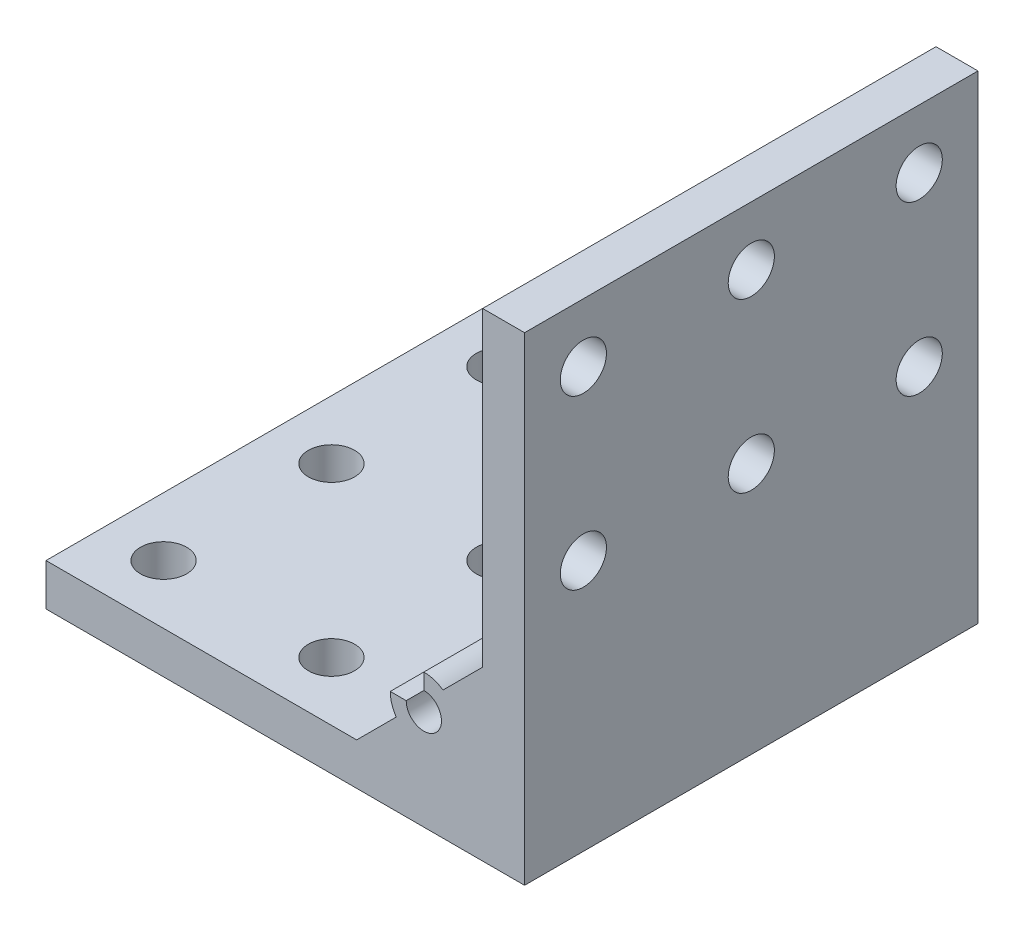
from build123d import *

# Parameters (mm, degrees)
BOSS_EXTRUDE1_DEPTH      = 27
BOSS_EXTRUDE1_DEPTH_BACK = 27
CUT_EXTRUDE1_REACH       = 79.479
SKETCH2_R                = 2.75
CUT_EXTRUDE2_REACH       = 79.479
SKETCH3_R                = 2.75


with BuildPart() as part:
    # Sketch1 → Boss-Extrude1 (new, two sides: drawn at the far end of the back side and taken through both)
    with BuildSketch(Plane.XY.offset(-BOSS_EXTRUDE1_DEPTH_BACK)):
        with BuildLine():
            Line((-8, -7), (-3.283882181, -2.283882181))
            ThreePointArc((-3.283882181, -2.283882181), (-3.816774078, -1.196760476), (-4, 0))
            Line((-4, 0), (-2.1, 0))
            ThreePointArc((-2.1, 0), (1.48492424, -1.48492424), (0, 2.1))
            Line((0, 2.1), (0, 4))
            ThreePointArc((0, 4), (1.196760476, 3.816774078), (2.283882181, 3.283882181))
            Line((2.283882181, 3.283882181), (7, 8))
            Line((7, 8), (7, 45))
            Line((7, 45), (12, 45))
            Line((12, 45), (12, -12))
            Line((12, -12), (-45, -12))
            Line((-45, -12), (-45, -7))
            Line((-45, -7), (-8, -7))
        make_face()
    extrude(amount=BOSS_EXTRUDE1_DEPTH + BOSS_EXTRUDE1_DEPTH_BACK)

    # Sketch2 → Cut-Extrude1 (cut, up to next)
    with BuildSketch(Plane(origin=(12, 0, 0), x_dir=(0, 0, -1), z_dir=(1, 0, 0)), mode=Mode.PRIVATE) as cut_extrude1_sk1:
        with Locations((-20, 38)):
            Circle(SKETCH2_R)
    cut_extrude1_tool1 = extrude(cut_extrude1_sk1.sketch, amount=-CUT_EXTRUDE1_REACH, mode=Mode.PRIVATE) & part.part
    # Sketch2 → Cut-Extrude1 (cut, up to next)
    with BuildSketch(Plane(origin=(12, 0, 0), x_dir=(0, 0, -1), z_dir=(1, 0, 0)), mode=Mode.PRIVATE) as cut_extrude1_sk2:
        with Locations((0, 38)):
            Circle(SKETCH2_R)
    cut_extrude1_tool2 = extrude(cut_extrude1_sk2.sketch, amount=-CUT_EXTRUDE1_REACH, mode=Mode.PRIVATE) & part.part
    # Sketch2 → Cut-Extrude1 (cut, up to next)
    with BuildSketch(Plane(origin=(12, 0, 0), x_dir=(0, 0, -1), z_dir=(1, 0, 0)), mode=Mode.PRIVATE) as cut_extrude1_sk3:
        with Locations((20, 38)):
            Circle(SKETCH2_R)
    cut_extrude1_tool3 = extrude(cut_extrude1_sk3.sketch, amount=-CUT_EXTRUDE1_REACH, mode=Mode.PRIVATE) & part.part
    # Sketch2 → Cut-Extrude1 (cut, up to next)
    with BuildSketch(Plane(origin=(12, 0, 0), x_dir=(0, 0, -1), z_dir=(1, 0, 0)), mode=Mode.PRIVATE) as cut_extrude1_sk4:
        with Locations((-20, 18)):
            Circle(SKETCH2_R)
    cut_extrude1_tool4 = extrude(cut_extrude1_sk4.sketch, amount=-CUT_EXTRUDE1_REACH, mode=Mode.PRIVATE) & part.part
    # Sketch2 → Cut-Extrude1 (cut, up to next)
    with BuildSketch(Plane(origin=(12, 0, 0), x_dir=(0, 0, -1), z_dir=(1, 0, 0)), mode=Mode.PRIVATE) as cut_extrude1_sk5:
        with Locations((0, 18)):
            Circle(SKETCH2_R)
    cut_extrude1_tool5 = extrude(cut_extrude1_sk5.sketch, amount=-CUT_EXTRUDE1_REACH, mode=Mode.PRIVATE) & part.part
    # Sketch2 → Cut-Extrude1 (cut, up to next)
    with BuildSketch(Plane(origin=(12, 0, 0), x_dir=(0, 0, -1), z_dir=(1, 0, 0)), mode=Mode.PRIVATE) as cut_extrude1_sk6:
        with Locations((20, 18)):
            Circle(SKETCH2_R)
    cut_extrude1_tool6 = extrude(cut_extrude1_sk6.sketch, amount=-CUT_EXTRUDE1_REACH, mode=Mode.PRIVATE) & part.part
    add(cut_extrude1_tool1.solids().sort_by_distance((12, 38, 20))[0], mode=Mode.SUBTRACT)
    add(cut_extrude1_tool2.solids().sort_by_distance((12, 38, 0))[0], mode=Mode.SUBTRACT)
    add(cut_extrude1_tool3.solids().sort_by_distance((12, 38, -20))[0], mode=Mode.SUBTRACT)
    add(cut_extrude1_tool4.solids().sort_by_distance((12, 18, 20))[0], mode=Mode.SUBTRACT)
    add(cut_extrude1_tool5.solids().sort_by_distance((12, 18, 0))[0], mode=Mode.SUBTRACT)
    add(cut_extrude1_tool6.solids().sort_by_distance((12, 18, -20))[0], mode=Mode.SUBTRACT)

    # Sketch3 → Cut-Extrude2 (cut, up to next)
    with BuildSketch(Plane.XZ.offset(12), mode=Mode.PRIVATE) as cut_extrude2_sk1:
        with Locations((-38, -20)):
            Circle(SKETCH3_R)
    cut_extrude2_tool1 = extrude(cut_extrude2_sk1.sketch, amount=-CUT_EXTRUDE2_REACH, mode=Mode.PRIVATE) & part.part
    # Sketch3 → Cut-Extrude2 (cut, up to next)
    with BuildSketch(Plane.XZ.offset(12), mode=Mode.PRIVATE) as cut_extrude2_sk2:
        with Locations((-38, 0)):
            Circle(SKETCH3_R)
    cut_extrude2_tool2 = extrude(cut_extrude2_sk2.sketch, amount=-CUT_EXTRUDE2_REACH, mode=Mode.PRIVATE) & part.part
    # Sketch3 → Cut-Extrude2 (cut, up to next)
    with BuildSketch(Plane.XZ.offset(12), mode=Mode.PRIVATE) as cut_extrude2_sk3:
        with Locations((-38, 20)):
            Circle(SKETCH3_R)
    cut_extrude2_tool3 = extrude(cut_extrude2_sk3.sketch, amount=-CUT_EXTRUDE2_REACH, mode=Mode.PRIVATE) & part.part
    # Sketch3 → Cut-Extrude2 (cut, up to next)
    with BuildSketch(Plane.XZ.offset(12), mode=Mode.PRIVATE) as cut_extrude2_sk4:
        with Locations((-18, -20)):
            Circle(SKETCH3_R)
    cut_extrude2_tool4 = extrude(cut_extrude2_sk4.sketch, amount=-CUT_EXTRUDE2_REACH, mode=Mode.PRIVATE) & part.part
    # Sketch3 → Cut-Extrude2 (cut, up to next)
    with BuildSketch(Plane.XZ.offset(12), mode=Mode.PRIVATE) as cut_extrude2_sk5:
        with Locations((-18, 0)):
            Circle(SKETCH3_R)
    cut_extrude2_tool5 = extrude(cut_extrude2_sk5.sketch, amount=-CUT_EXTRUDE2_REACH, mode=Mode.PRIVATE) & part.part
    # Sketch3 → Cut-Extrude2 (cut, up to next)
    with BuildSketch(Plane.XZ.offset(12), mode=Mode.PRIVATE) as cut_extrude2_sk6:
        with Locations((-18, 20)):
            Circle(SKETCH3_R)
    cut_extrude2_tool6 = extrude(cut_extrude2_sk6.sketch, amount=-CUT_EXTRUDE2_REACH, mode=Mode.PRIVATE) & part.part
    add(cut_extrude2_tool1.solids().sort_by_distance((-38, -12, -20))[0], mode=Mode.SUBTRACT)
    add(cut_extrude2_tool2.solids().sort_by_distance((-38, -12, 0))[0], mode=Mode.SUBTRACT)
    add(cut_extrude2_tool3.solids().sort_by_distance((-38, -12, 20))[0], mode=Mode.SUBTRACT)
    add(cut_extrude2_tool4.solids().sort_by_distance((-18, -12, -20))[0], mode=Mode.SUBTRACT)
    add(cut_extrude2_tool5.solids().sort_by_distance((-18, -12, 0))[0], mode=Mode.SUBTRACT)
    add(cut_extrude2_tool6.solids().sort_by_distance((-18, -12, 20))[0], mode=Mode.SUBTRACT)


solid = part.part
